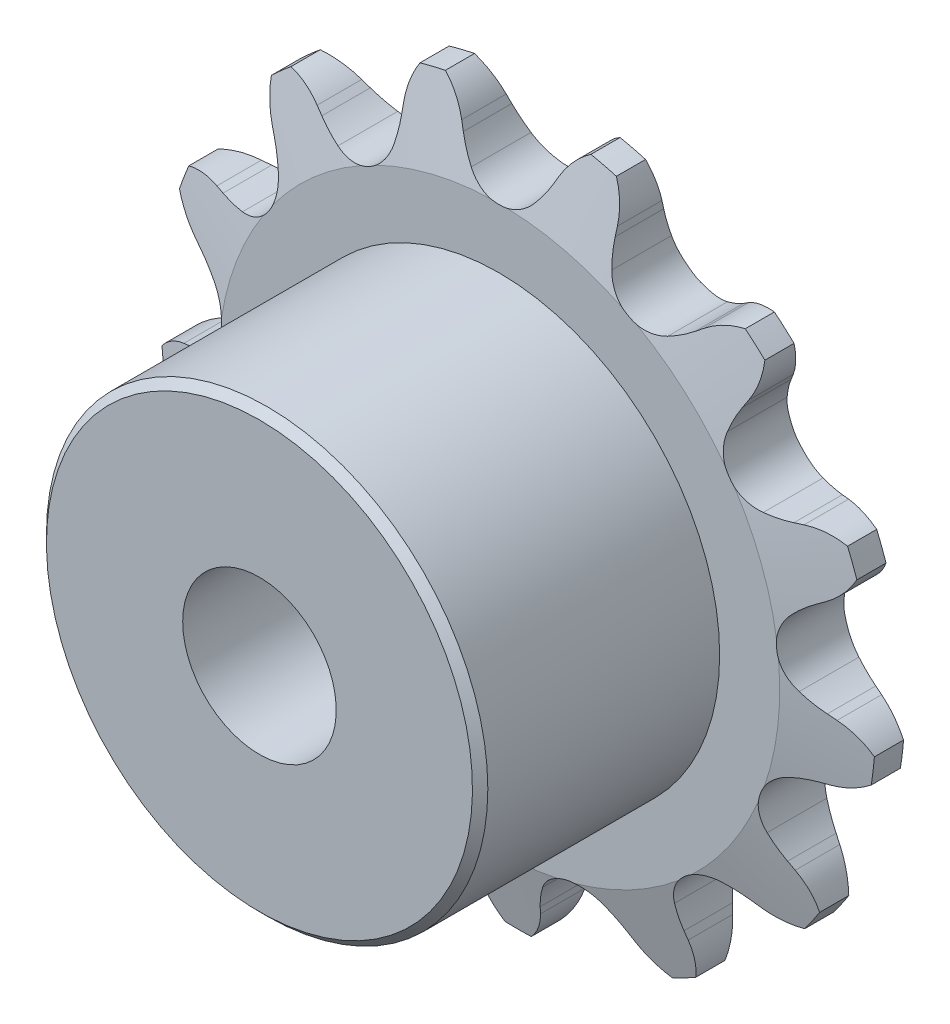
from build123d import *

# Parameters (mm, degrees)
CUT_EXTRUDE1_DEPTH      = 21.957854648
CIRPATTERN1_COUNT       = 13
BOSS_EXTRUDE1_START     = 1.397
SKETCH2_R               = 9.128125
BOSS_EXTRUDE1_DEPTH     = 9.906
CUT_EXTRUDE2_DEPTH      = 24.738017509
CUT_EXTRUDE2_DEPTH_BACK = 24.738017509
SKETCH3_R               = 3.175
SKETCH4_W               = 2.0955
SKETCH4_H               = 5.461


with BuildPart() as part:
    # Sketch1 → Revolve1 (revolve)
    with BuildSketch(Plane(origin=(0, 0, 0), x_dir=(0, 0, -1), z_dir=(1, 0, 0)), mode=Mode.PRIVATE) as revolve1_sk:
        Polygon((1.397, 0), (-1.397, 0), (-1.397, 11.611481367), (-0.60325, 14.786481367), (0.60325, 14.786481367), (1.397, 11.611481367), align=None)
    revolve(revolve1_sk.sketch.rotate(Axis((0, 0, -1.397), (0, 0, 1)), 90), axis=Axis((0, 0, -1.397), (0, 0, 1)))

    # Sketch0 → Cut-Extrude1 (cut, symmetric)
    with BuildSketch(Plane.XY):
        with BuildLine():
            Line((5.156053003, -12.491084497), (4.937329729, -12.228277815))
            ThreePointArc((4.937329729, -12.228277815), (4.582686216, -11.850519212), (4.185541119, -11.517728954))
            ThreePointArc((4.185541119, -11.517728954), (2.768796361, -11.233448418), (1.64644293, -12.14356045))
            ThreePointArc((1.64644293, -12.14356045), (1.449443755, -12.622794118), (1.310975696, -13.122093808))
            Line((1.310975696, -13.122093808), (1.239438209, -13.456443341))
            ThreePointArc((1.239438209, -13.456443341), (0.157953109, -15.111590651), (-1.754732567, -15.612346223))
            ThreePointArc((-1.754732567, -15.612346223), (3.759804013, -15.254124516), (8.809157585, -13.008581154))
            ThreePointArc((8.809157585, -13.008581154), (6.88284581, -13.454053469), (5.156053003, -12.491084497))
        make_face()
    cut_extrude1 = extrude(amount=CUT_EXTRUDE1_DEPTH, both=True, mode=Mode.SUBTRACT)

    # CirPattern1: Cut-Extrude1 ×13 about axis
    cirpattern1_axis = Axis((0, 0, 0), (0, 0, 1))
    for i in range(1, CIRPATTERN1_COUNT):
        add(cut_extrude1.rotate(cirpattern1_axis, i * 360 / CIRPATTERN1_COUNT), mode=Mode.SUBTRACT)

    # Sketch2 → Boss-Extrude1 (add)
    with BuildSketch(Plane.XY.offset(BOSS_EXTRUDE1_START)):
        Circle(SKETCH2_R)
    extrude(amount=BOSS_EXTRUDE1_DEPTH)

    # Sketch3 → Cut-Extrude2 (cut, two sides: drawn at the far end of the back side and taken through both)
    with BuildSketch(Plane.XY.offset(-CUT_EXTRUDE2_DEPTH_BACK)):
        with Locations(Location((0, 0, 0), (0, 0, 180))):
            Circle(SKETCH3_R)
    extrude(amount=CUT_EXTRUDE2_DEPTH + CUT_EXTRUDE2_DEPTH_BACK, mode=Mode.SUBTRACT)

    # Sketch4 → Cut-Revolve1 (revolve, cut)
    with BuildSketch(Plane(origin=(0, 0, 0), x_dir=(0, 0, -1), z_dir=(1, 0, 0))):
        Polygon((-11.303, 9.128125), (-11.303, 8.810625), (-10.9855, 9.128125), align=None)
        with Locations((-2.44475, 12.055981367)):
            Rectangle(SKETCH4_W, SKETCH4_H)
    revolve(axis=Axis((0, 0, -1.397), (0, 0, 1)), mode=Mode.SUBTRACT)


solid = part.part
